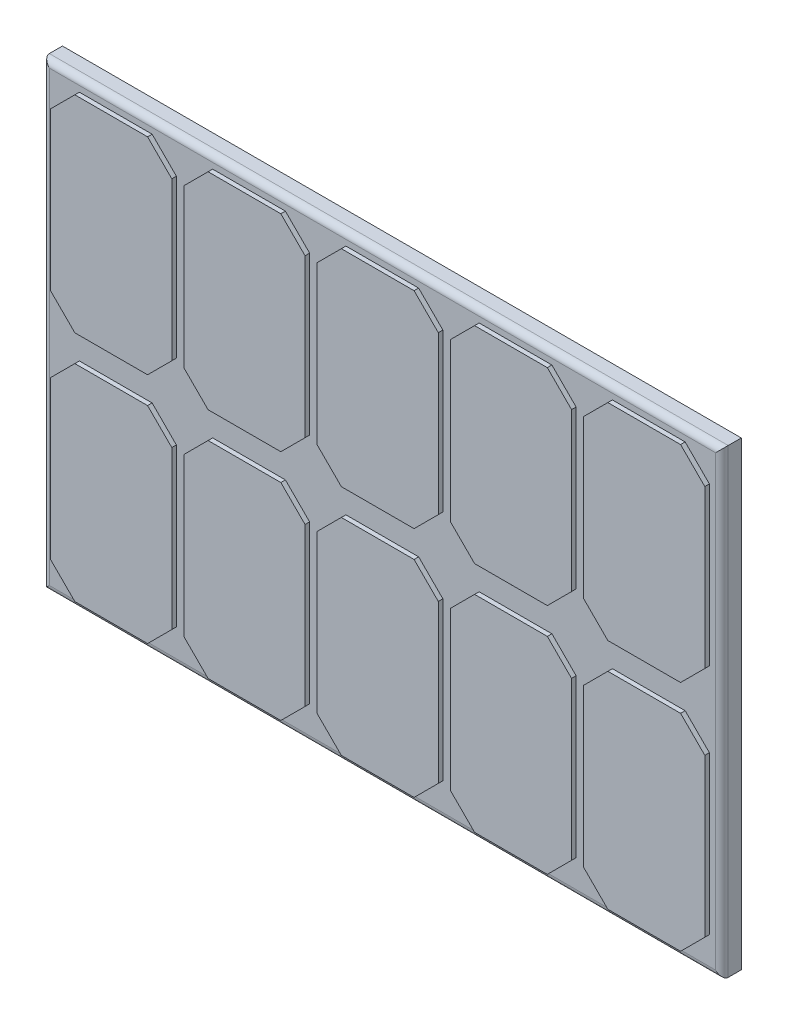
from build123d import *

# Parameters (mm, degrees)
SKETCH1_W                   = 88.9
SKETCH1_H                   = 60.325
SOLARPANELPLASTICBASE_DEPTH = 2.54
CRYSTALELEMENT_DEPTH        = 0.5969
OUTSIDEFILLET_R             = 0.8255
LPATTERN1_COUNT             = 5
LPATTERN1_PITCH             = 17.4498
LPATTERN1_COUNT_DIR2        = 2
LPATTERN1_PITCH_DIR2        = 30.48


with BuildPart() as part:
    # Sketch1 → SolarPanelPlasticBase (new body)
    with BuildSketch(Plane.XY):
        Rectangle(SKETCH1_W, SKETCH1_H)
    extrude(amount=SOLARPANELPLASTICBASE_DEPTH)

    # Sketch2 → CrystalElement (add)
    with BuildSketch(Plane.XY.offset(2.54)):
        Polygon((-39.6875, 28.575), (-30.1625, 28.575), (-26.9875, 25.4), (-26.9875, 4.7625), (-30.1625, 1.5875), (-39.6875, 1.5875), (-42.8625, 4.7625), (-42.8625, 25.4), align=None)
    crystalelement = extrude(amount=CRYSTALELEMENT_DEPTH)

    # OutsideFillet
    outsidefillet_edges = [part.edges().sort_by_distance(p)[0] for p in [
        (44.45, 0, 2.54),
        (0, 30.1625, 2.54),
        (-44.45, 0, 2.54),
        (0, -30.1625, 2.54),
    ]]
    fillet(outsidefillet_edges, radius=OUTSIDEFILLET_R)

    # LPattern1: CrystalElement 5 × 2
    with Locations(*[(i * LPATTERN1_PITCH, -j * LPATTERN1_PITCH_DIR2, 0) for i in range(LPATTERN1_COUNT) for j in range(LPATTERN1_COUNT_DIR2) if (i, j) != (0, 0)]):
        add(crystalelement)


solid = part.part
